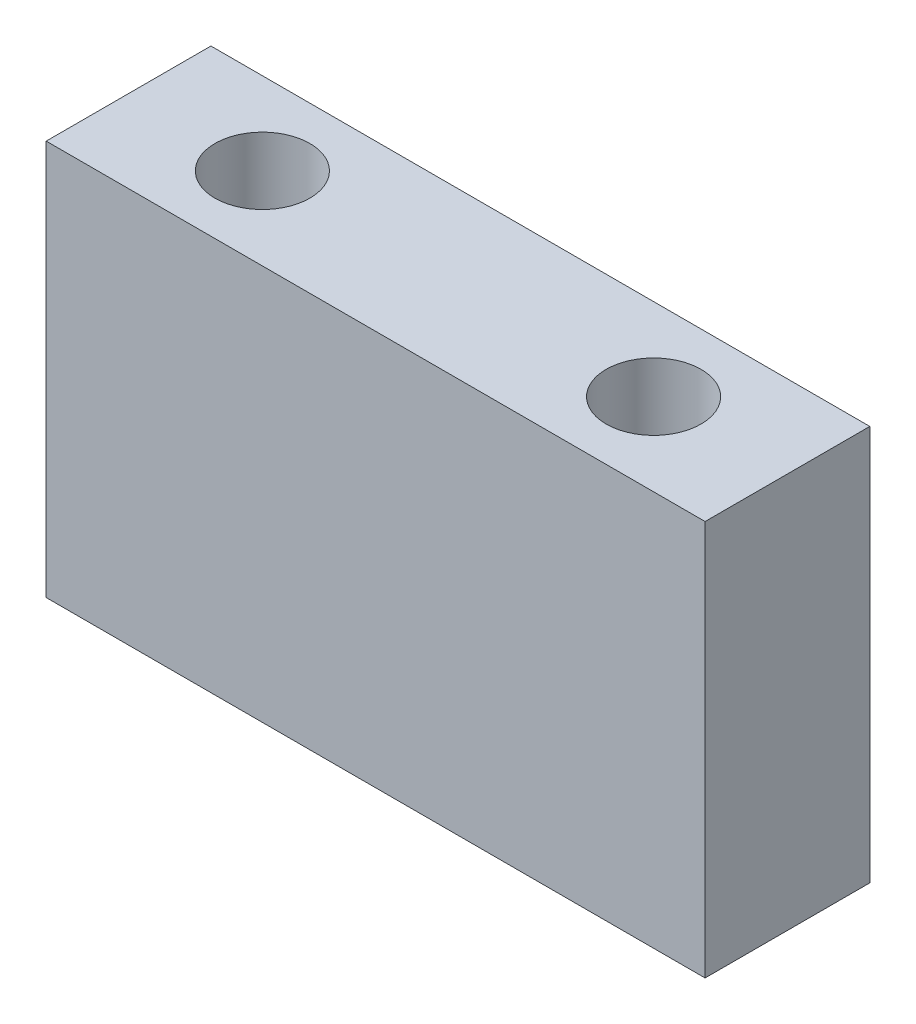
from build123d import *

# Parameters (mm, degrees)
SKETCH1_W                 = 25.4
SKETCH1_H                 = 6.35
BOSS_EXTRUDE1_DEPTH       = 15.24
F_6_CLEARANCE_HOLE1_D     = 3.6576
F_6_CLEARANCE_HOLE1_DEPTH = 15.24


with BuildPart() as part:
    # Sketch1 → Boss-Extrude1 (new body)
    with BuildSketch(Plane(origin=(0, 0, 0), x_dir=(1, 0, 0), z_dir=(0, 1, 0))):
        with Locations((-21.553599873, 9.404005603)):
            Rectangle(SKETCH1_W, SKETCH1_H)
    extrude(amount=BOSS_EXTRUDE1_DEPTH)

    # #6 Clearance Hole1
    with Locations(Plane(origin=(0, 15.24, 0), x_dir=(-1, 0, 0), z_dir=(0, 1, 0))):
        with Locations((29.094224873, -9.404005603), (14.012974873, -9.404005603)):
            Hole(F_6_CLEARANCE_HOLE1_D / 2, depth=F_6_CLEARANCE_HOLE1_DEPTH)


solid = part.part
